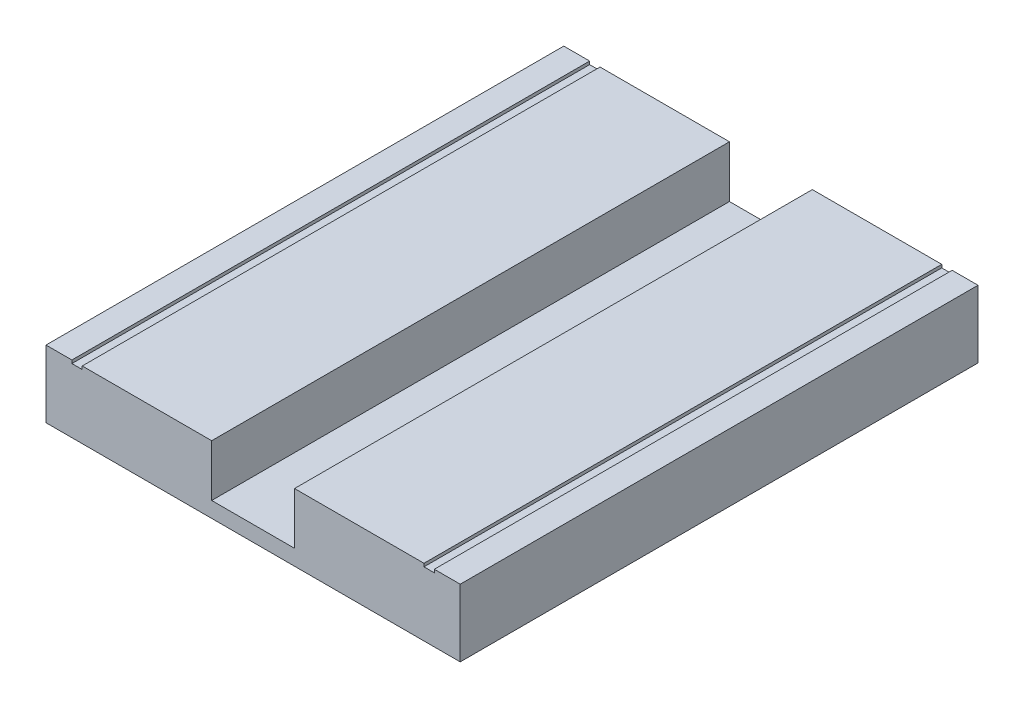
from build123d import *

# Parameters (mm, degrees)
ESQUISSE3_W             = 80
ESQUISSE3_H             = 10
EXTRU_MINCE4_DEPTH      = 100
ESQUISSE4_W             = 2
ESQUISSE4_H             = 100
ENL_V_MAT_EXTRU_1_DEPTH = 0.6
ENL_V_MAT_EXTRU_2_DEPTH = 11
ESQUISSE6_W             = 80
ESQUISSE6_H             = 100
BOSS_EXTRU_1_DEPTH      = 3


with BuildPart() as part:
    # Esquisse3 → Extru.-Mince4 (new body)
    with BuildSketch(Plane.XY):
        with Locations((0, -5)):
            Rectangle(ESQUISSE3_W, ESQUISSE3_H)
    extrude(amount=EXTRU_MINCE4_DEPTH)

    # Esquisse4 → Enlèv. mat.-Extru.1 (cut)
    with BuildSketch(Plane(origin=(0, 0, 0), x_dir=(1, 0, 0), z_dir=(0, 1, 0))):
        with Locations((-34, -50)):
            Rectangle(ESQUISSE4_W, ESQUISSE4_H)
        with Locations((34, -50)):
            Rectangle(ESQUISSE4_W, ESQUISSE4_H)
    extrude(amount=-ENL_V_MAT_EXTRU_1_DEPTH, mode=Mode.SUBTRACT)

    # Esquisse5 → Enlèv. mat.-Extru.2 (cut)
    with BuildSketch(Plane(origin=(0, 0, 0), x_dir=(1, 0, 0), z_dir=(0, 1, 0))):
        Polygon((0, 0), (-8, 0), (-8, -100), (8, -100), (8, 0), align=None)
    extrude(amount=-ENL_V_MAT_EXTRU_2_DEPTH, mode=Mode.SUBTRACT)

    # Esquisse6 → Boss.-Extru.1 (add)
    with BuildSketch(Plane.XZ.offset(10)):
        with Locations((0, 50)):
            Rectangle(ESQUISSE6_W, ESQUISSE6_H)
    extrude(amount=BOSS_EXTRU_1_DEPTH)


solid = part.part
